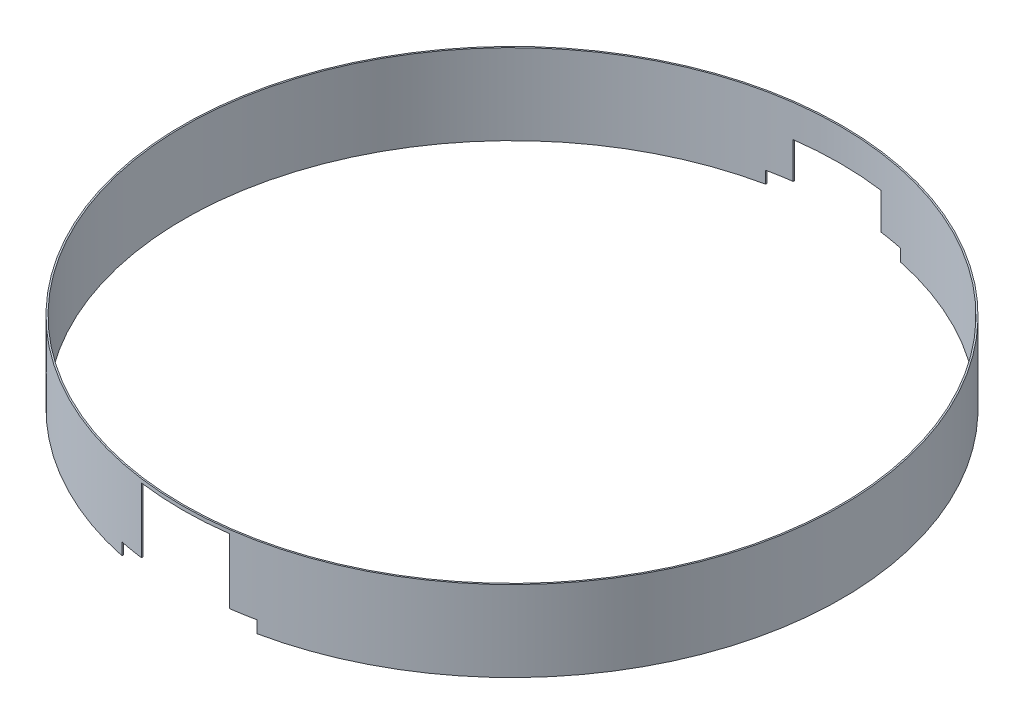
from build123d import *

# Parameters (mm, degrees)
CROQUIS1_R              = 450
CROQUIS1_R_2            = 448
SALIENTE_EXTRUIR2_DEPTH = 110
CROQUIS2_W              = 120
CROQUIS2_H              = 210
CROQUIS2_W_2            = 32
CROQUIS2_H_2            = 16.5
CORTAR_EXTRUIR2_DEPTH   = 500
CROQUIS3_W              = 120
CROQUIS3_H              = 66
CROQUIS3_W_2            = 32
CROQUIS3_H_2            = 16.5
CORTAR_EXTRUIR3_DEPTH   = 500


with BuildPart() as part:
    # Croquis1 → Saliente-Extruir2 (new body)
    with BuildSketch(Plane(origin=(0, 0, 0), x_dir=(1, 0, 0), z_dir=(0, 1, 0))):
        Circle(CROQUIS1_R)
        Circle(CROQUIS1_R_2, mode=Mode.SUBTRACT)
    extrude(amount=SALIENTE_EXTRUIR2_DEPTH)

    # Croquis2 → Cortar-Extruir2 (cut)
    with BuildSketch(Plane.XY):
        Rectangle(CROQUIS2_W, CROQUIS2_H)
        with Locations((-76, 8.25)):
            Rectangle(CROQUIS2_W_2, CROQUIS2_H_2)
        with Locations((76, 8.25)):
            Rectangle(CROQUIS2_W_2, CROQUIS2_H_2)
    extrude(amount=CORTAR_EXTRUIR2_DEPTH, mode=Mode.SUBTRACT)

    # Croquis3 → Cortar-Extruir3 (cut)
    with BuildSketch(Plane.XY):
        with Locations((0, 33)):
            Rectangle(CROQUIS3_W, CROQUIS3_H)
        with Locations((76, 8.25)):
            Rectangle(CROQUIS3_W_2, CROQUIS3_H_2)
        with Locations((-76, 8.25)):
            Rectangle(CROQUIS3_W_2, CROQUIS3_H_2)
    extrude(amount=-CORTAR_EXTRUIR3_DEPTH, mode=Mode.SUBTRACT)


solid = part.part
